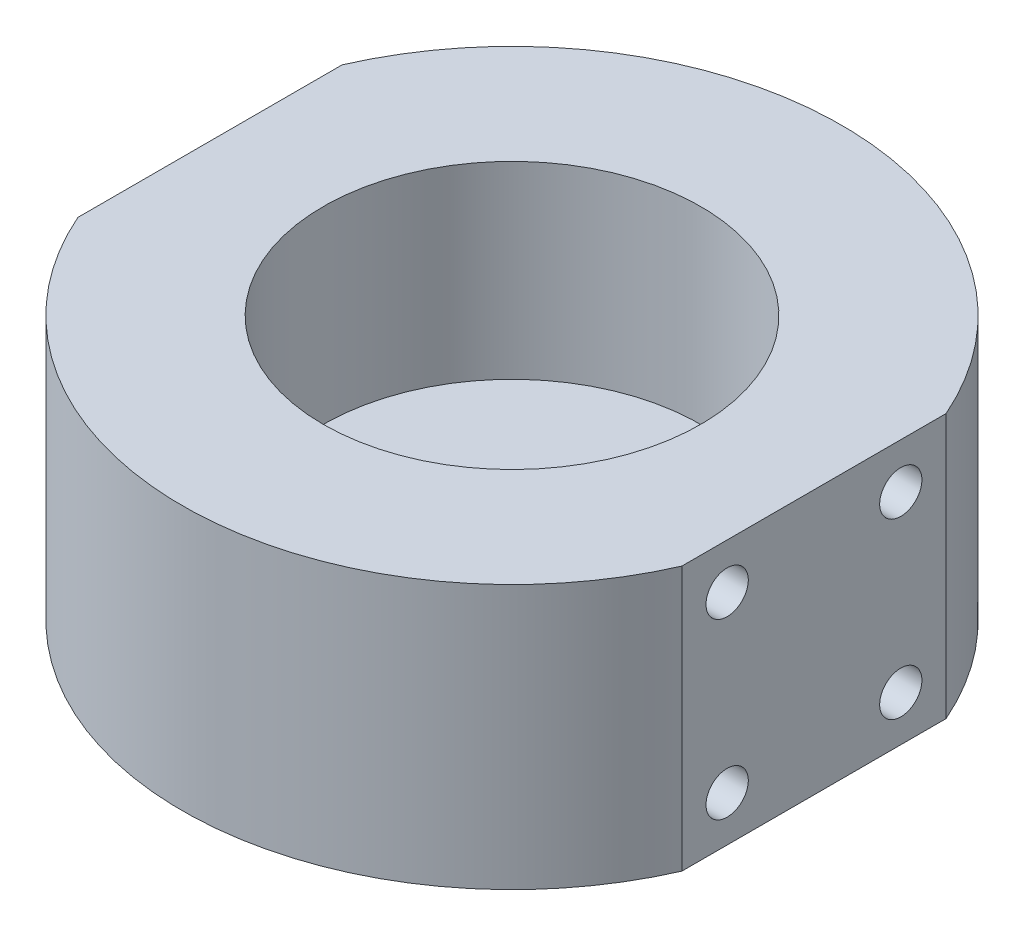
from build123d import *

# Parameters (mm, degrees)
BOSS_EXTRUDE1_DEPTH = 35
SKETCH2_R           = 2.8
CUT_EXTRUDE1_DEPTH  = 10
CUT_EXTRUDE2_START  = -80
SKETCH2_2_R         = 2.8
CUT_EXTRUDE2_DEPTH  = 10
SKETCH3_R           = 1.69
SKETCH3_R_2         = 2.25
CUT_EXTRUDE3_DEPTH  = 36
SKETCH4_R           = 25
CUT_EXTRUDE4_DEPTH  = 25


with BuildPart() as part:
    # Sketch1 → Boss-Extrude1 (new body)
    with BuildSketch(Plane(origin=(0, 0, 0), x_dir=(1, 0, 0), z_dir=(0, 1, 0))):
        with BuildLine():
            Line((-40, 17.5), (-40, -17.5))
            ThreePointArc((-40, -17.5), (0, -43.660622991), (40, -17.5))
            Line((40, -17.5), (40, 17.5))
            ThreePointArc((40, 17.5), (0, 43.660622991), (-40, 17.5))
        make_face()
    extrude(amount=BOSS_EXTRUDE1_DEPTH)

    # Sketch2 → Cut-Extrude1 (cut)
    with BuildSketch(Plane.ZY.offset(40)):
        with Locations((-11.5, 29)):
            Circle(SKETCH2_R)
        with Locations((11.5, 29)):
            Circle(SKETCH2_R)
        with Locations((-11.5, 6)):
            Circle(SKETCH2_R)
        with Locations((11.5, 6)):
            Circle(SKETCH2_R)
    extrude(amount=-CUT_EXTRUDE1_DEPTH, mode=Mode.SUBTRACT)

    # Sketch2_2 → Cut-Extrude2 (cut)
    with BuildSketch(Plane.ZY.offset(40).offset(CUT_EXTRUDE2_START)):
        with Locations((-11.5, 29)):
            Circle(SKETCH2_2_R)
        with Locations((11.5, 29)):
            Circle(SKETCH2_2_R)
        with Locations((-11.5, 6)):
            Circle(SKETCH2_2_R)
        with Locations((11.5, 6)):
            Circle(SKETCH2_2_R)
    extrude(amount=CUT_EXTRUDE2_DEPTH, mode=Mode.SUBTRACT)

    # Sketch3 → Cut-Extrude3 (cut, through all)
    with BuildSketch(Plane(origin=(0, 35, 0), x_dir=(1, 0, 0), z_dir=(0, 1, 0))):
        with Locations((0, 9)):
            Circle(SKETCH3_R)
        with Locations((6, 0)):
            Circle(SKETCH3_R)
        with Locations((0, -9)):
            Circle(SKETCH3_R)
        with Locations((-6, 0)):
            Circle(SKETCH3_R)
        Circle(SKETCH3_R_2)
    extrude(amount=-CUT_EXTRUDE3_DEPTH, mode=Mode.SUBTRACT)

    # Sketch4 → Cut-Extrude4 (cut)
    with BuildSketch(Plane(origin=(0, 35, 0), x_dir=(1, 0, 0), z_dir=(0, 1, 0))):
        Circle(SKETCH4_R)
    extrude(amount=-CUT_EXTRUDE4_DEPTH, mode=Mode.SUBTRACT)


solid = part.part
